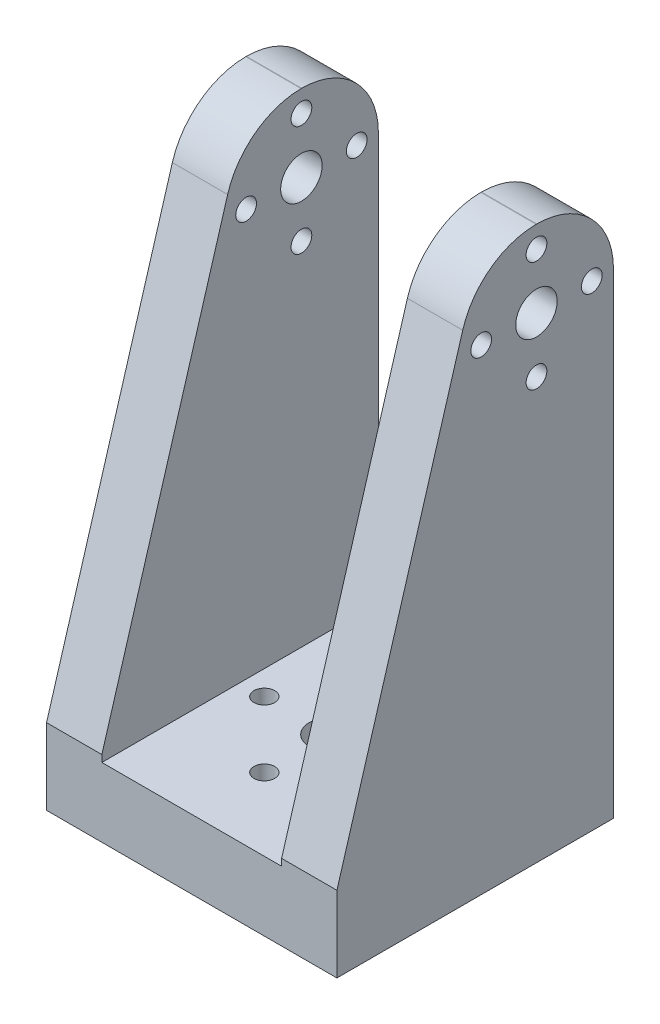
from build123d import *

# Parameters (mm, degrees)
DODANIE_WYCI_GNI_CIE1_DEPTH = 40
SZKIC2_R                    = 3
WYTNIJ_WYCI_GNI_CIE1_DEPTH  = 43
SZKIC3_R                    = 3
SZKIC3_R_2                  = 1.5
WYTNIJ_WYCI_GNI_CIE2_DEPTH  = 11
SZKIC4_R                    = 1.5
WYTNIJ_WYCI_GNI_CIE3_DEPTH  = 43


with BuildPart() as part:
    # Szkic1 → Dodanie-wyciągnięcie1 (new body)
    with BuildSketch(Plane.XY):
        Polygon((13, 10), (-13, 10), (-13, 80), (-21, 80), (-21, 0), (21, 0), (21, 80), (13, 80), align=None)
    extrude(amount=DODANIE_WYCI_GNI_CIE1_DEPTH)

    # Szkic2 → Wytnij-wyciągnięcie1 (cut, through all)
    with BuildSketch(Plane(origin=(21, 0, 0), x_dir=(0, 0, -1), z_dir=(1, 0, 0))):
        with BuildLine():
            Line((-40, 80), (-40, 10.986882517))
            Line((-40, 10.986882517), (-21.804909779, 72.045708909))
            ThreePointArc((-21.804909779, 72.045708909), (-17.808572792, 77.778071195), (-11.183339281, 80))
            Line((-11.183339281, 80), (-40, 80))
        make_face()
        with BuildLine():
            Line((-0.000389565, 68.866002091), (0, 10.986882517))
            Line((0, 10.986882517), (0, 80))
            Line((0, 80), (-11.085649948, 80))
            ThreePointArc((-11.085649948, 80), (-3.244243133, 76.721715095), (-0.000389565, 68.866002091))
        make_face()
        with Locations((-11.134494614, 68.866002091)):
            Circle(SZKIC2_R)
    extrude(amount=-WYTNIJ_WYCI_GNI_CIE1_DEPTH, mode=Mode.SUBTRACT)

    # Szkic3 → Wytnij-wyciągnięcie2 (cut, through all)
    with BuildSketch(Plane(origin=(0, 10, 0), x_dir=(1, 0, 0), z_dir=(0, 1, 0))):
        with Locations((0, -20)):
            Circle(SZKIC3_R)
        with Locations((0, -10.5)):
            Circle(SZKIC3_R_2)
        with Locations((9.5, -20)):
            Circle(SZKIC3_R_2)
        with Locations((0, -29.5)):
            Circle(SZKIC3_R_2)
        with Locations((-9.5, -20)):
            Circle(SZKIC3_R_2)
    extrude(amount=-WYTNIJ_WYCI_GNI_CIE2_DEPTH, mode=Mode.SUBTRACT)

    # Szkic4 → Wytnij-wyciągnięcie3 (cut, through all)
    with BuildSketch(Plane.ZY.offset(21)):
        with Locations((3.134494614, 68.866002091)):
            Circle(SZKIC4_R)
        with Locations((11.134494614, 76.866002091)):
            Circle(SZKIC4_R)
        with Locations((19.134494614, 68.866002091)):
            Circle(SZKIC4_R)
        with Locations((11.134494614, 60.866002091)):
            Circle(SZKIC4_R)
    extrude(amount=-WYTNIJ_WYCI_GNI_CIE3_DEPTH, mode=Mode.SUBTRACT)


solid = part.part
